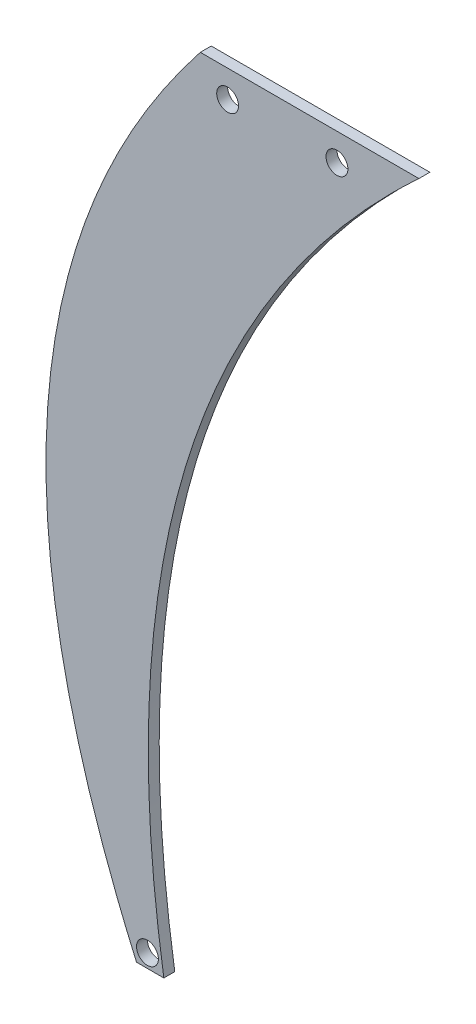
from build123d import *

# Parameters (mm, degrees)
EXTRUDE_1_DEPTH     = 2
SKETCH_2_R          = 2
CUT_EXTRUDE_1_DEPTH = 3.0000001


with BuildPart() as part:
    # Эскиз1 → Бобышка-Вытянуть1 (new body)
    with BuildSketch(Plane.XY):
        with BuildLine():
            Line((0, 0), (40, 0))
            add(Edge.make_bspline(
                [(40, 0), (-21.389317784, -56.818064534), (-6.67027027, -150)],
                knots=[0, 0, 0, 1, 1, 1], degree=2))
            Line((-6.67027027, -150), (-11.67027027, -150))
            add(Edge.make_bspline(
                [(0, 0), (-49.854113681, -63.235965622), (-11.67027027, -150)],
                knots=[0, 0, 0, 1, 1, 1], degree=2))
        make_face()
    extrude(amount=EXTRUDE_1_DEPTH)

    # Эскиз2 → Вырез-Вытянуть1 (cut, through all)
    with BuildSketch(Plane.XY.offset(2)):
        with Locations((5, -5)):
            Circle(SKETCH_2_R)
        with Locations((25, -5)):
            Circle(SKETCH_2_R)
        with Locations((-9.67027027, -147.5)):
            Circle(SKETCH_2_R)
    extrude(amount=-CUT_EXTRUDE_1_DEPTH, mode=Mode.SUBTRACT)


solid = part.part
